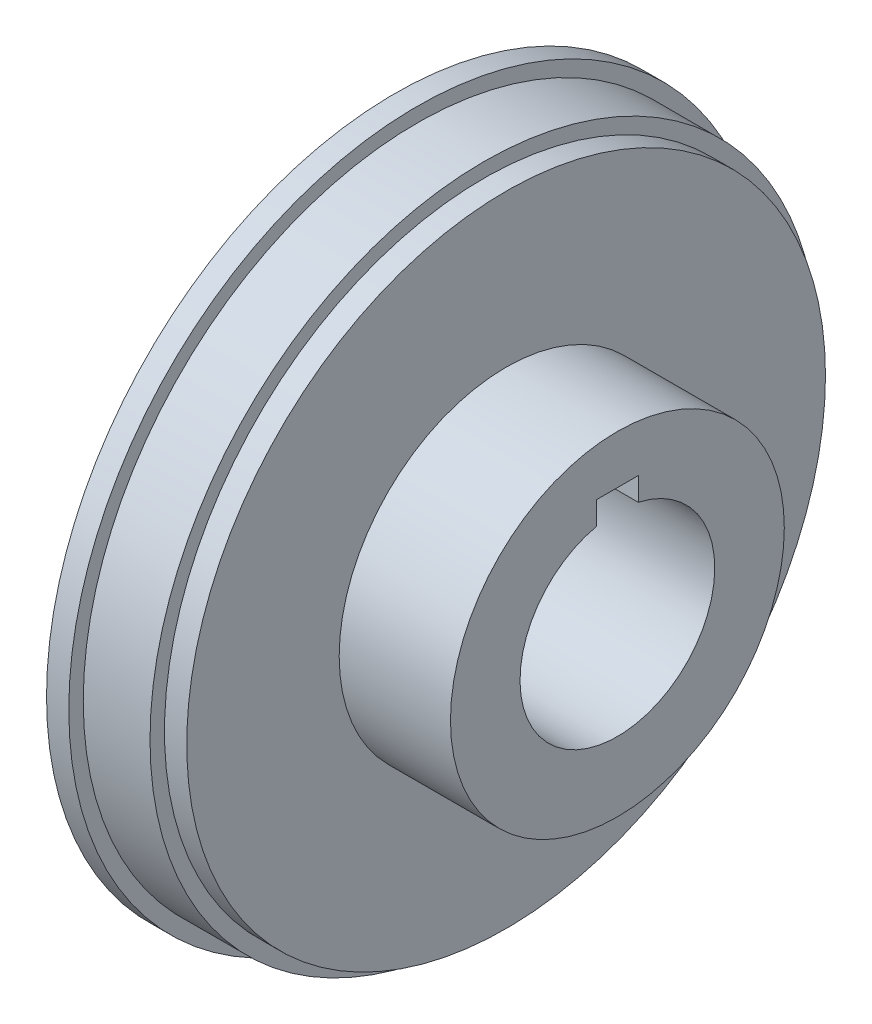
from build123d import *

# Parameters (mm, degrees)
SKETCH1_R           = 25.4
BOSS_EXTRUDE1_DEPTH = 25.4
SKETCH2_R           = 38.1
SKETCH2_R_2         = 19.05
BOSS_EXTRUDE2_DEPTH = 12.7
SKETCH3_R           = 25.4
SKETCH3_R_2         = 19.05
CUT_EXTRUDE1_DEPTH  = 12.7
SKETCH5_R           = 39.751
SKETCH5_R_2         = 38.1
BOSS_EXTRUDE3_DEPTH = 2.54
SKETCH6_R           = 38.1
SKETCH6_R_2         = 36.449
CUT_EXTRUDE3_DEPTH  = 2.54


with BuildPart() as part:
    # Sketch1 → Boss-Extrude1 (new body)
    with BuildSketch(Plane(origin=(0, 0, 0), x_dir=(0, 0, -1), z_dir=(1, 0, 0))):
        Circle(SKETCH1_R)
        with BuildLine():
            Line((-2.38125, 10.854368), (-2.38125, 13.49375))
            Line((-2.38125, 13.49375), (2.38125, 13.49375))
            Line((2.38125, 13.49375), (2.38125, 10.854368))
            ThreePointArc((2.38125, 10.854368), (8.658790241, 6.965127982), (11.1125, 0))
            ThreePointArc((11.1125, 0), (-6.965127982, -8.658790241), (-2.38125, 10.854368))
        make_face(mode=Mode.SUBTRACT)
    extrude(amount=BOSS_EXTRUDE1_DEPTH)

    # Sketch2 → Boss-Extrude2 (add)
    with BuildSketch(Plane.ZY):
        Circle(SKETCH2_R)
        Circle(SKETCH2_R_2, mode=Mode.SUBTRACT)
    extrude(amount=-BOSS_EXTRUDE2_DEPTH)

    # Sketch3 → Cut-Extrude1 (cut)
    with BuildSketch(Plane(origin=(25.4, 0, 0), x_dir=(0, 0, -1), z_dir=(1, 0, 0))):
        Circle(SKETCH3_R)
        Circle(SKETCH3_R_2, mode=Mode.SUBTRACT)
    extrude(amount=-CUT_EXTRUDE1_DEPTH, mode=Mode.SUBTRACT)

    # Sketch5 → Boss-Extrude3 (add)
    with BuildSketch(Plane.ZY):
        Circle(SKETCH5_R)
        Circle(SKETCH5_R_2, mode=Mode.SUBTRACT)
    extrude(amount=-BOSS_EXTRUDE3_DEPTH)

    # Sketch6 → Cut-Extrude3 (cut)
    with BuildSketch(Plane(origin=(12.7, 0, 0), x_dir=(0, 0, -1), z_dir=(1, 0, 0))):
        Circle(SKETCH6_R)
        Circle(SKETCH6_R_2, mode=Mode.SUBTRACT)
    extrude(amount=-CUT_EXTRUDE3_DEPTH, mode=Mode.SUBTRACT)


solid = part.part
